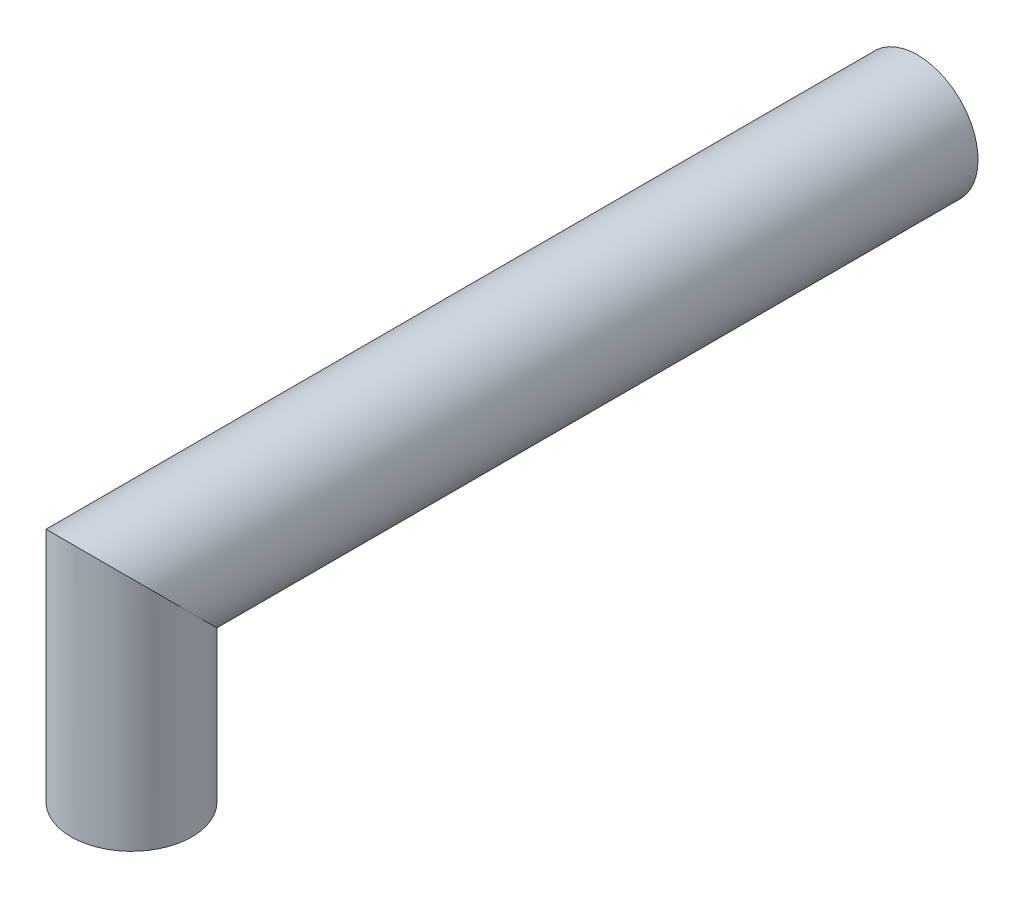
from build123d import *

# Parameters (mm, degrees)
SKETCH1_R = 5


with BuildPart() as part:
    # Sweep1: sweep along a path in Sketch2
    with BuildLine(Plane(origin=(0, 0, 0), x_dir=(0, 0, -1), z_dir=(1, 0, 0))) as sweep1_path:
        Line((0, 0), (0, 16))
        Line((0, 16), (65, 16))
    # Sketch1 → Sweep1 (sweep)
    with BuildSketch(Plane(origin=(0, 0, 0), x_dir=(1, 0, 0), z_dir=(0, 1, 0))):
        Circle(SKETCH1_R)
    sweep(path=sweep1_path.line, transition=Transition.RIGHT)


solid = part.part
